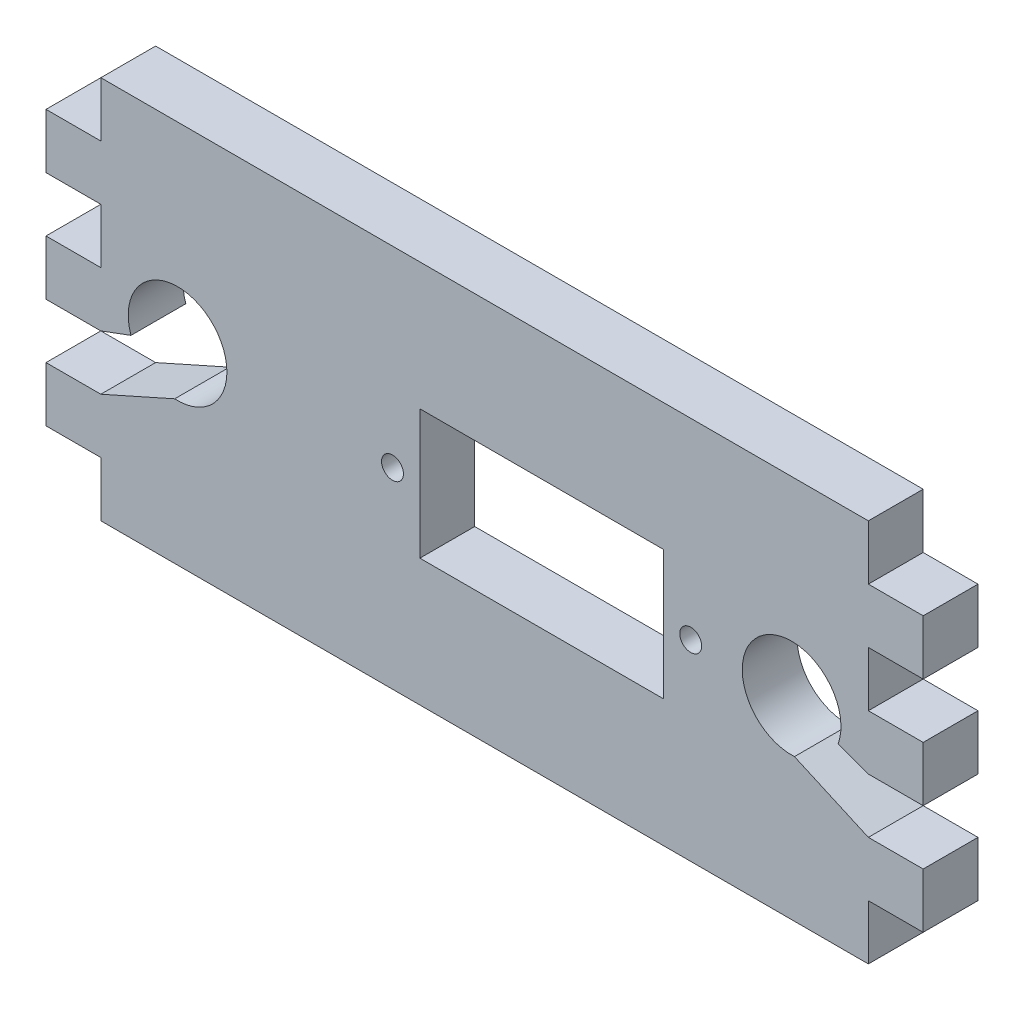
from build123d import *

# Parameters (mm, degrees)
ESQUISSE1_W                = 80
ESQUISSE1_H                = 35
BOSS_EXTRU_1_DEPTH         = 5
ESQUISSE3_W                = 5
ESQUISSE3_H                = 5
ENL_V_MAT_EXTRU_1_DEPTH    = 10
R_P_TITION_LIN_AIRE1_COUNT = 4
R_P_TITION_LIN_AIRE1_PITCH = 10
ESQUISSE4_W                = 5
ESQUISSE4_H                = 5
ENL_V_MAT_EXTRU_2_DEPTH    = 10
R_P_TITION_LIN_AIRE2_COUNT = 4
R_P_TITION_LIN_AIRE2_PITCH = 10
ESQUISSE6_W                = 22.2
ESQUISSE6_H                = 11.8
ENL_V_MAT_EXTRU_5_DEPTH    = 10
ESQUISSE7_R                = 1
ESQUISSE7_R_2              = 0.999214349
ENL_V_MAT_EXTRU_7_DEPTH    = 10
ESQUISSE8_R                = 4.5
ENL_V_MAT_EXTRU_8_DEPTH    = 10
ENL_V_MAT_EXTRU_9_DEPTH    = 10


with BuildPart() as part:
    # Esquisse1 → Boss.-Extru.1 (new body)
    with BuildSketch(Plane.XY):
        Rectangle(ESQUISSE1_W, ESQUISSE1_H)
    extrude(amount=BOSS_EXTRU_1_DEPTH)

    # Esquisse3 → Enlèv. mat.-Extru.1 (cut)
    with BuildSketch(Plane.XY):
        with Locations((37.5, -15)):
            Rectangle(ESQUISSE3_W, ESQUISSE3_H)
    enl_v_mat_extru_1 = extrude(amount=ENL_V_MAT_EXTRU_1_DEPTH, mode=Mode.SUBTRACT)

    # Répétition linéaire1: Enlèv. mat.-Extru.1 ×4
    with Locations(*[(0, i * R_P_TITION_LIN_AIRE1_PITCH, 0) for i in range(1, R_P_TITION_LIN_AIRE1_COUNT)]):
        add(enl_v_mat_extru_1, mode=Mode.SUBTRACT)

    # Esquisse4 → Enlèv. mat.-Extru.2 (cut)
    with BuildSketch(Plane.XY):
        with Locations((-37.5, -15)):
            Rectangle(ESQUISSE4_W, ESQUISSE4_H)
    enl_v_mat_extru_2 = extrude(amount=ENL_V_MAT_EXTRU_2_DEPTH, mode=Mode.SUBTRACT)

    # Répétition linéaire2: Enlèv. mat.-Extru.2 ×4
    with Locations(*[(0, i * R_P_TITION_LIN_AIRE2_PITCH, 0) for i in range(1, R_P_TITION_LIN_AIRE2_COUNT)]):
        add(enl_v_mat_extru_2, mode=Mode.SUBTRACT)

    # Esquisse6 → Enlèv. mat.-Extru.5 (cut)
    with BuildSketch(Plane.XY):
        with Locations((5.2, 0)):
            Rectangle(ESQUISSE6_W, ESQUISSE6_H)
    extrude(amount=ENL_V_MAT_EXTRU_5_DEPTH, mode=Mode.SUBTRACT)

    # Esquisse7 → Enlèv. mat.-Extru.7 (cut)
    with BuildSketch(Plane.XY):
        with Locations((18.8, 0)):
            Circle(ESQUISSE7_R)
        with Locations((-8.4, 0)):
            Circle(ESQUISSE7_R_2)
    extrude(amount=ENL_V_MAT_EXTRU_7_DEPTH, mode=Mode.SUBTRACT)

    # Esquisse8 → Enlèv. mat.-Extru.8 (cut)
    with BuildSketch(Plane(origin=(0, 0, 0), x_dir=(-1, 0, 0), z_dir=(0, 0, -1))):
        with Locations((28, 0)):
            Circle(ESQUISSE8_R)
    enl_v_mat_extru_8 = extrude(amount=-ENL_V_MAT_EXTRU_8_DEPTH, mode=Mode.SUBTRACT)

    # Esquisse9 → Enlèv. mat.-Extru.9 (cut)
    with BuildSketch(Plane(origin=(0, 0, 0), x_dir=(-1, 0, 0), z_dir=(0, 0, -1))):
        Polygon((32.25, -1.479019946), (35, -2.5), (35, -7.5), (28.260126937, -4.492475262), align=None)
    enl_v_mat_extru_9 = extrude(amount=-ENL_V_MAT_EXTRU_9_DEPTH, mode=Mode.SUBTRACT)

    # Symétrie1: Enlèv. mat.-Extru.8, Enlèv. mat.-Extru.9 across plane
    add(enl_v_mat_extru_8.mirror(Plane(origin=(0, 0, 0), x_dir=(0, 0, 1), z_dir=(1, 0, 0))), mode=Mode.SUBTRACT)
    add(enl_v_mat_extru_9.mirror(Plane(origin=(0, 0, 0), x_dir=(0, 0, 1), z_dir=(1, 0, 0))), mode=Mode.SUBTRACT)


solid = part.part
